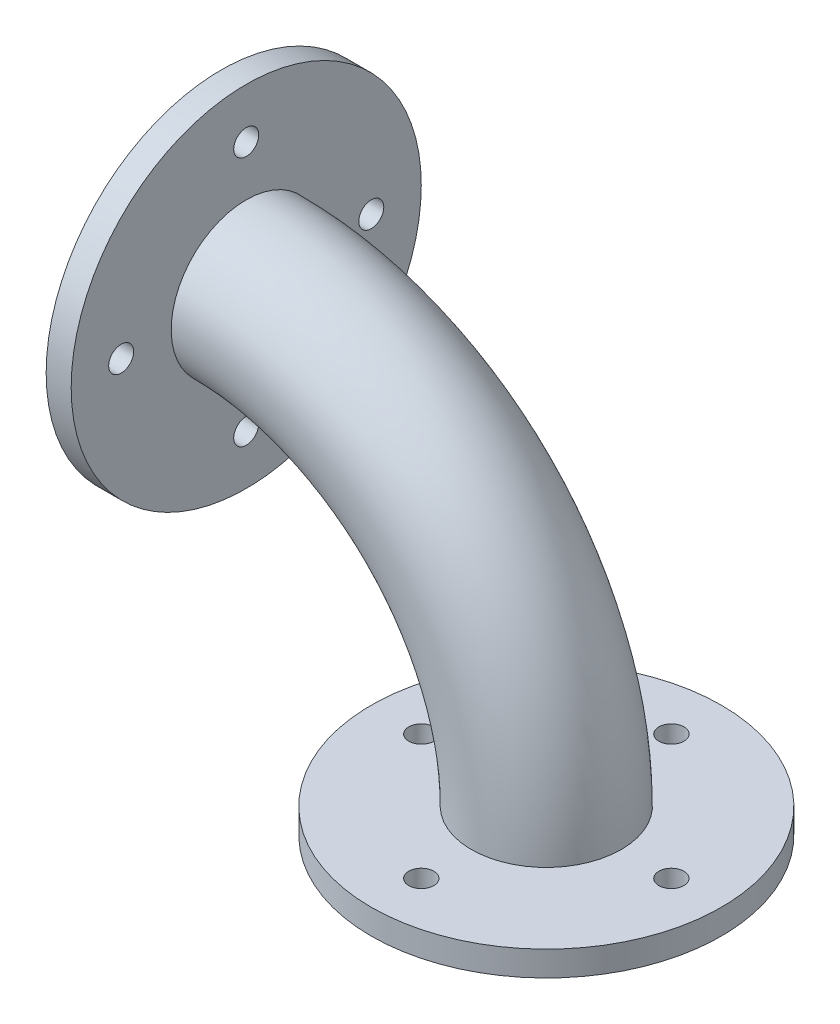
from build123d import *

# Parameters (mm, degrees)
SKETCH3_R           = 19.05
SKETCH3_R_2         = 12.7
SKETCH4_R           = 44.45
SKETCH4_R_2         = 3.175
BOSS_EXTRUDE1_DEPTH = 6.35


with BuildPart() as part:
    # Sweep1: sweep along a path in Sketch1
    with BuildLine(Plane.XY) as sweep1_path:
        ThreePointArc((76.2, 0), (52.411249779, 55.31275528), (-4.101860805, 76.089517924))
    # Sketch3 → Sweep1 (sweep)
    with BuildSketch(Plane(origin=(0, 0, 0), x_dir=(1, 0, 0), z_dir=(0, 1, 0))):
        with Locations((76.2, 0)):
            Circle(SKETCH3_R)
        with Locations((76.2, 0)):
            Circle(SKETCH3_R_2, mode=Mode.SUBTRACT)
    sweep(path=sweep1_path.line)

    # Sketch4 → Boss-Extrude1 (add)
    with BuildSketch(Plane.XZ):
        with Locations((76.2, 0)):
            Circle(SKETCH4_R)
        with Locations((76.2, 31.75)):
            Circle(SKETCH4_R_2, mode=Mode.SUBTRACT)
        with Locations((107.95, 0)):
            Circle(SKETCH4_R_2, mode=Mode.SUBTRACT)
        with Locations((76.2, -31.75)):
            Circle(SKETCH4_R_2, mode=Mode.SUBTRACT)
        with Locations((44.45, 0)):
            Circle(SKETCH4_R_2, mode=Mode.SUBTRACT)
    boss_extrude1 = extrude(amount=BOSS_EXTRUDE1_DEPTH)

    # Mirror1: Boss-Extrude1 across plane
    add(boss_extrude1.mirror(Plane(origin=(0, 0, 0), x_dir=(0, 0, 1), z_dir=(-0.7071067811865488, 0.7071067811865464, 0))))


solid = part.part
